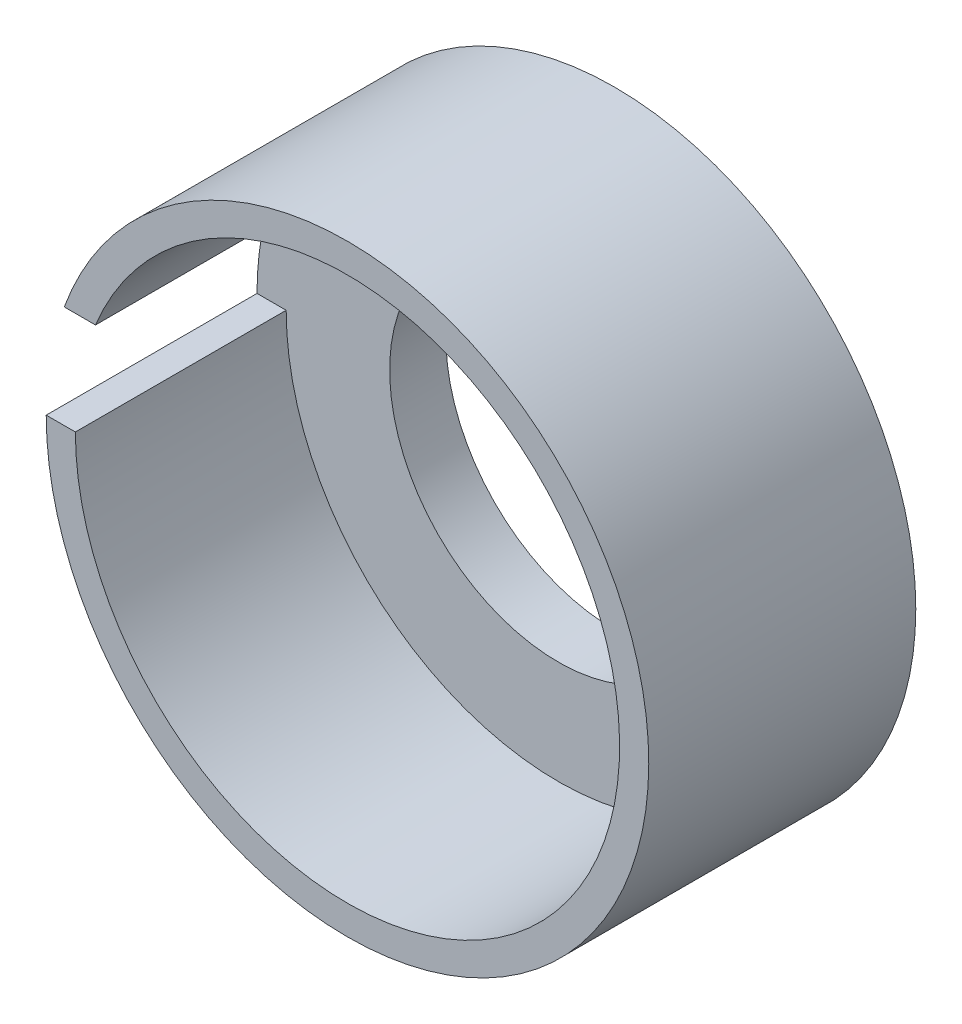
from build123d import *

# Parameters (mm, degrees)
SKETCH1_R           = 42.875
BOSS_EXTRUDE1_DEPTH = 8
BOSS_EXTRUDE2_DEPTH = 30
SKETCH4_R           = 24
CUT_EXTRUDE1_DEPTH  = 20


with BuildPart() as part:
    # Sketch1 → Boss-Extrude1 (new body)
    with BuildSketch(Plane.XY):
        Circle(SKETCH1_R)
    extrude(amount=BOSS_EXTRUDE1_DEPTH)

    # Sketch2 → Boss-Extrude2 (add)
    with BuildSketch(Plane.XY.offset(8)):
        with BuildLine():
            ThreePointArc((38.725, 0), (0, -38.725), (-38.725, 0))
            Line((-38.725, 0), (-42.875, 0))
            ThreePointArc((-42.875, 0), (0, -42.875), (42.875, 0))
            ThreePointArc((42.875, 0), (7.419974343, 42.228066564), (-40.30678919, 14.616031274))
            Line((-40.30678919, 14.616031274), (-35.860803878, 14.616031274))
            ThreePointArc((-35.860803878, 14.616031274), (7.44701265, 38.002205562), (38.725, 0))
        make_face()
    extrude(amount=BOSS_EXTRUDE2_DEPTH)

    # Sketch4 → Cut-Extrude1 (cut)
    with BuildSketch(Plane.XY.offset(8)):
        Circle(SKETCH4_R)
    extrude(amount=-CUT_EXTRUDE1_DEPTH, mode=Mode.SUBTRACT)


solid = part.part
